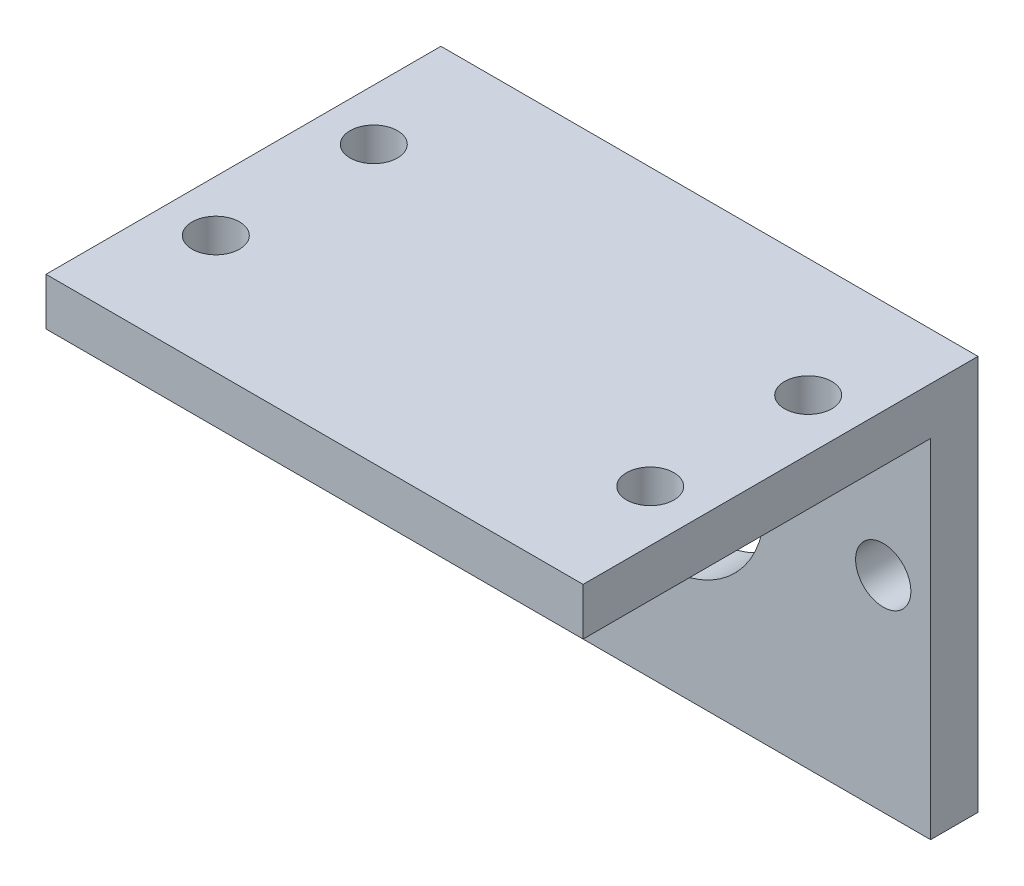
from build123d import *

# Parameters (mm, degrees)
SKETCH_1_W          = 68
SKETCH_1_H          = 50
SKETCH_1_R          = 3
EXTRUDE_1_DEPTH     = 6
SKETCH_3_W          = 68
SKETCH_3_H          = 6
EXTRUDE_2_DEPTH     = 50
CUT_EXTRUDE_1_REACH = 8
SKETCH_4_R          = 13
SKETCH_4_R_2        = 3.5


with BuildPart() as part:
    # 草图1 → 凸台-拉伸1 (new body)
    with BuildSketch(Plane(origin=(0, 0, 0), x_dir=(1, 0, 0), z_dir=(0, 1, 0))):
        with Locations((0, 25)):
            Rectangle(SKETCH_1_W, SKETCH_1_H)
        with Locations((-27.5, 35)):
            Circle(SKETCH_1_R, mode=Mode.SUBTRACT)
        with Locations((27.5, 35)):
            Circle(SKETCH_1_R, mode=Mode.SUBTRACT)
        with Locations((-27.5, 15)):
            Circle(SKETCH_1_R, mode=Mode.SUBTRACT)
        with Locations((27.5, 15)):
            Circle(SKETCH_1_R, mode=Mode.SUBTRACT)
    extrude(amount=EXTRUDE_1_DEPTH)

    # 草图3 → 凸台-拉伸2 (add)
    with BuildSketch(Plane(origin=(0, 6, 0), x_dir=(1, 0, 0), z_dir=(0, 1, 0))):
        with Locations((0, 47)):
            Rectangle(SKETCH_3_W, SKETCH_3_H)
    extrude(amount=-EXTRUDE_2_DEPTH)

    # 草图4 → 切除-拉伸1 (cut, up to next)
    with BuildSketch(Plane.XY.offset(-44), mode=Mode.PRIVATE) as cut_extrude_1_sk1:
        with Locations((0, -18)):
            Circle(SKETCH_4_R)
    cut_extrude_1_tool1 = extrude(cut_extrude_1_sk1.sketch, amount=-CUT_EXTRUDE_1_REACH, mode=Mode.PRIVATE) & part.part
    add(cut_extrude_1_tool1.solids().sort_by_distance((0, -18, -44))[0], mode=Mode.SUBTRACT)
    # 草图4 → 切除-拉伸1 (cut, up to next)
    with BuildSketch(Plane.XY.offset(-44), mode=Mode.PRIVATE) as cut_extrude_1_sk2:
        with Locations((28, -18)):
            Circle(SKETCH_4_R_2)
    cut_extrude_1_tool2 = extrude(cut_extrude_1_sk2.sketch, amount=-CUT_EXTRUDE_1_REACH, mode=Mode.PRIVATE) & part.part
    add(cut_extrude_1_tool2.solids().sort_by_distance((28, -18, -44))[0], mode=Mode.SUBTRACT)
    # 草图4 → 切除-拉伸1 (cut, up to next)
    with BuildSketch(Plane.XY.offset(-44), mode=Mode.PRIVATE) as cut_extrude_1_sk3:
        with Locations((-28, -18)):
            Circle(SKETCH_4_R_2)
    cut_extrude_1_tool3 = extrude(cut_extrude_1_sk3.sketch, amount=-CUT_EXTRUDE_1_REACH, mode=Mode.PRIVATE) & part.part
    add(cut_extrude_1_tool3.solids().sort_by_distance((-28, -18, -44))[0], mode=Mode.SUBTRACT)


solid = part.part
